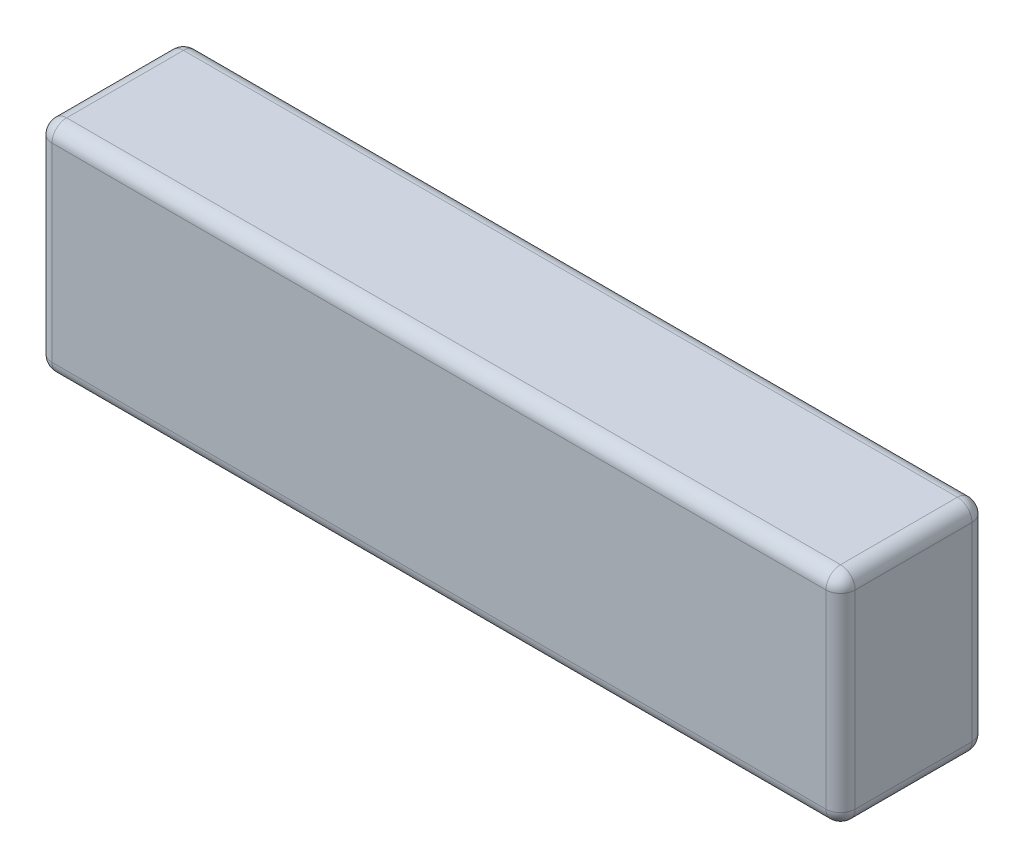
from build123d import *

# Parameters (mm, degrees)
SKETCH1_W           = 165
SKETCH1_H           = 45
BOSS_EXTRUDE1_DEPTH = 30
FILLET1_R           = 3
SKETCH3_W           = 0.673076923
SKETCH3_H           = 3.58974359
CUT_EXTRUDE1_DEPTH  = 1


with BuildPart() as part:
    # Sketch1 → Boss-Extrude1 (new body)
    with BuildSketch(Plane.XY):
        Rectangle(SKETCH1_W, SKETCH1_H)
    extrude(amount=BOSS_EXTRUDE1_DEPTH)

    # Fillet1
    fillet1_edges = [part.edges().sort_by_distance(p)[0] for p in [
        (-82.5, 0, 30),
        (0, -22.5, 30),
        (82.5, 0, 30),
        (0, -22.5, 0),
        (-82.5, 0, 0),
        (0, 22.5, 0),
        (82.5, 0, 0),
        (82.5, -22.5, 15),
        (-82.5, -22.5, 15),
        (-82.5, 22.5, 15),
        (82.5, 22.5, 15),
        (0, 22.5, 30),
    ]]
    fillet(fillet1_edges, radius=FILLET1_R)

    # Sketch3 → Cut-Extrude1 (cut)
    with BuildSketch(Plane(origin=(0, 0, 0), x_dir=(-1, 0, 0), z_dir=(0, 0, -1))):
        with BuildLine():
            Line((-71.893671292, 13.895700482), (-71.280189722, 14.073084296))
            add(Edge.make_bspline(
                [(-71.280189722, 14.073084296), (-71.225871314, 14.026443619), (-71.11859737, 13.934332501), (-70.945097923, 13.816329924), (-70.766422915, 13.715059698), (-70.581148594, 13.63270496), (-70.389377495, 13.5683925), (-70.191163217, 13.52318746), (-69.986740392, 13.49481596), (-69.84835797, 13.491451935), (-69.778386837, 13.489750962)],
                knots=[0, 0, 0, 0, 1.041270537, 2.056415149, 3.04785222, 4.02691907, 5.002476125, 5.986793017, 6.982050086, 8, 8, 8, 8], degree=3))
            add(Edge.make_bspline(
                [(-69.778386837, 13.489750962), (-69.718520811, 13.490595629), (-69.600453579, 13.492261472), (-69.426293871, 13.508397473), (-69.257568488, 13.533099502), (-69.096761926, 13.568729231), (-68.947474644, 13.611362634), (-68.815323909, 13.663057693), (-68.701557084, 13.720805312), (-68.607697907, 13.785963271), (-68.532945551, 13.855419315), (-68.479830433, 13.928754235), (-68.444745019, 14.004465283), (-68.440584367, 14.057084306), (-68.438543087, 14.082900001)],
                knots=[0, 0, 0, 0, 1.365842901, 2.693702937, 3.988022121, 5.254898597, 6.449778871, 7.52732281, 8.488639893, 9.354185358, 10.127518264, 10.803926709, 11.413188221, 12, 12, 12, 12], degree=3))
            add(Edge.make_bspline(
                [(-68.438543087, 14.082900001), (-68.439112411, 14.097481047), (-68.440270162, 14.127132398), (-68.453455005, 14.170899726), (-68.472231153, 14.215136997), (-68.500258895, 14.258225052), (-68.534745365, 14.301733666), (-68.578504597, 14.343168824), (-68.627943234, 14.386701505), (-68.665641594, 14.412809149), (-68.685337959, 14.42644968)],
                knots=[0, 0, 0, 0, 0.793399885, 1.613421822, 2.475989874, 3.41027112, 4.408291548, 5.499676526, 6.693649214, 8, 8, 8, 8], degree=3))
            add(Edge.make_bspline(
                [(-68.685337959, 14.42644968), (-68.716434597, 14.446676446), (-68.783238704, 14.490129086), (-68.895335349, 14.551825517), (-69.024674541, 14.616738622), (-69.171169098, 14.685778315), (-69.336143806, 14.755631459), (-69.517927066, 14.830458881), (-69.717496484, 14.907137439), (-69.856838004, 14.958102229), (-69.929128023, 14.984542629)],
                knots=[0, 0, 0, 0, 0.651554612, 1.399718012, 2.246232405, 3.194032661, 4.244274998, 5.393334075, 6.647668484, 8, 8, 8, 8], degree=3))
            add(Edge.make_bspline(
                [(-69.929128023, 14.984542629), (-69.966034542, 14.998150046), (-70.03818007, 15.024750071), (-70.144166452, 15.06282844), (-70.244296243, 15.100823125), (-70.338777419, 15.137486352), (-70.428376271, 15.171491034), (-70.512104805, 15.205700026), (-70.591423778, 15.236350772), (-70.664276575, 15.268020517), (-70.732699706, 15.296269706), (-70.795118504, 15.324353287), (-70.852469629, 15.350341477), (-70.904262321, 15.37506123), (-70.951325938, 15.397408854), (-70.991932824, 15.420808434), (-71.028407185, 15.440155565), (-71.050067787, 15.454158992), (-71.060037478, 15.460604328)],
                knots=[0, 0, 0, 0, 1.536708746, 3.003985981, 4.399603778, 5.720466992, 6.96332443, 8.143356599, 9.253876673, 10.28491013, 11.246410331, 12.14563761, 12.958693125, 13.706093678, 14.387997087, 14.992804235, 15.536419603, 16, 16, 16, 16], degree=3))
            add(Edge.make_bspline(
                [(-71.060037478, 15.460604328), (-71.090549913, 15.480904245), (-71.148884037, 15.519713928), (-71.227209146, 15.583555978), (-71.294817191, 15.64752261), (-71.348696344, 15.714491245), (-71.392146428, 15.781744391), (-71.422738135, 15.850962612), (-71.440879821, 15.921958303), (-71.443602949, 15.969754729), (-71.444953344, 15.993456892)],
                knots=[0, 0, 0, 0, 1.281965709, 2.450881021, 3.532631345, 4.532915139, 5.45200979, 6.327405019, 7.170563115, 8, 8, 8, 8], degree=3))
            add(Edge.make_bspline(
                [(-71.444953344, 15.993456892), (-71.44427483, 16.012198355), (-71.442923955, 16.049511327), (-71.432090545, 16.105020964), (-71.413434595, 16.158884889), (-71.388985904, 16.212189444), (-71.356168838, 16.263375515), (-71.316691868, 16.313376098), (-71.269851875, 16.361801811), (-71.216786678, 16.409288266), (-71.157132258, 16.454942155), (-71.090905368, 16.497433074), (-71.019236456, 16.538047404), (-70.942290796, 16.576849084), (-70.858868809, 16.611672582), (-70.769925263, 16.644470185), (-70.675290914, 16.675420444), (-70.540404354, 16.712882475), (-70.36324456, 16.751922991), (-70.142524092, 16.786573613), (-69.912416763, 16.805966925), (-69.756219345, 16.808814524), (-69.676724177, 16.810263783)],
                knots=[0, 0, 0, 0, 0.533177814, 1.061520582, 1.602115444, 2.15264519, 2.726586989, 3.328082654, 3.963210978, 4.641558391, 5.353326044, 6.098707271, 6.879203721, 7.697260024, 8.549721912, 9.45048688, 10.39496421, 11.38267535, 13.433851354, 15.554349609, 17.737429174, 20, 20, 20, 20], degree=3))
            add(Edge.make_bspline(
                [(-69.676724177, 16.810263783), (-69.592299393, 16.808876627), (-69.425907832, 16.806142703), (-69.180366201, 16.78165738), (-68.943338436, 16.741786215), (-68.750859531, 16.695742834), (-68.599683291, 16.648660214), (-68.484793001, 16.607660889), (-68.368885975, 16.558591791), (-68.250840835, 16.504003787), (-68.131379942, 16.44236293), (-68.010317125, 16.373947626), (-67.887775806, 16.299115369), (-67.806658115, 16.245196251), (-67.765466164, 16.217815866)],
                knots=[0, 0, 0, 0, 1.493185142, 2.942896577, 4.360030623, 5.74281349, 6.439800385, 7.160372375, 7.899781663, 8.665559224, 9.460651888, 10.277042986, 11.125074197, 12, 12, 12, 12], degree=3))
            Line((-67.765466164, 16.217815866), (-68.354408472, 16.002571475))
            add(Edge.make_bspline(
                [(-68.354408472, 16.002571475), (-68.387938207, 16.024733576), (-68.453069722, 16.067783461), (-68.550217321, 16.127439043), (-68.643106415, 16.181505429), (-68.732488681, 16.229339136), (-68.818004729, 16.271602827), (-68.899934038, 16.307912511), (-68.977780392, 16.339373795), (-69.077640812, 16.371845173), (-69.202630714, 16.404448241), (-69.357346339, 16.431801889), (-69.518391008, 16.447971016), (-69.62807622, 16.450172362), (-69.683735395, 16.451289424)],
                knots=[0, 0, 0, 0, 1.01325678, 1.968251433, 2.873777025, 3.72260486, 4.523687185, 5.27809884, 5.981646049, 6.639388114, 7.924189992, 9.234888461, 10.596858935, 12, 12, 12, 12], degree=3))
            add(Edge.make_bspline(
                [(-69.683735395, 16.451289424), (-69.719497069, 16.450816342), (-69.789428885, 16.449891231), (-69.891957304, 16.444695669), (-69.989456255, 16.433878832), (-70.082073923, 16.41986813), (-70.169894664, 16.403037039), (-70.252250227, 16.379903526), (-70.330068619, 16.354609809), (-70.401882811, 16.324505231), (-70.466746691, 16.291846404), (-70.524003422, 16.257596473), (-70.572917446, 16.221668411), (-70.612033298, 16.18223911), (-70.643503611, 16.141855096), (-70.665640182, 16.098837794), (-70.679876592, 16.054184338), (-70.681382768, 16.023473969), (-70.682132831, 16.008180449)],
                knots=[0, 0, 0, 0, 1.453597553, 2.842504444, 4.170504916, 5.438658546, 6.649524212, 7.801703064, 8.913104635, 9.973318417, 10.963111014, 11.862343011, 12.683042548, 13.421876713, 14.113400648, 14.754904574, 15.379952374, 16, 16, 16, 16], degree=3))
            add(Edge.make_bspline(
                [(-70.682132831, 16.008180449), (-70.680843563, 15.98933836), (-70.678222367, 15.951030707), (-70.658586135, 15.894663115), (-70.627801081, 15.839213074), (-70.583460936, 15.783886791), (-70.522532208, 15.728231378), (-70.442333903, 15.672235217), (-70.342780423, 15.613326149), (-70.268499403, 15.576034468), (-70.22850703, 15.555956892)],
                knots=[0, 0, 0, 0, 0.670740552, 1.363675461, 2.105758115, 2.924217645, 3.879278919, 5.03765473, 6.405094373, 8, 8, 8, 8], degree=3))
            add(Edge.make_bspline(
                [(-70.22850703, 15.555956892), (-70.22172353, 15.552933402), (-70.206531136, 15.546161963), (-70.181617855, 15.534626535), (-70.150893563, 15.523397599), (-70.11623971, 15.507800912), (-70.075319499, 15.493133325), (-70.029833953, 15.475386342), (-69.979462175, 15.455703652), (-69.924071504, 15.434669534), (-69.86361443, 15.41242903), (-69.79839038, 15.387549386), (-69.727735354, 15.361805261), (-69.651872304, 15.334620091), (-69.571418222, 15.304924263), (-69.485694703, 15.274356097), (-69.395238768, 15.241021834), (-69.332963717, 15.218887556), (-69.300922895, 15.20749936)],
                knots=[0, 0, 0, 0, 0.359733916, 0.80566378, 1.32905273, 1.942911142, 2.64507461, 3.433374686, 4.307824936, 5.264358505, 6.303026488, 7.427805646, 8.645357254, 9.945110068, 11.330930719, 12.798956541, 14.353047294, 16, 16, 16, 16], degree=3))
            add(Edge.make_bspline(
                [(-69.300922895, 15.20749936), (-69.226287183, 15.179909903), (-69.082448241, 15.126739132), (-68.876473322, 15.046545776), (-68.688934732, 14.968086865), (-68.519968919, 14.89171346), (-68.368847587, 14.818423919), (-68.23613182, 14.747368183), (-68.121840328, 14.677922983), (-68.024646019, 14.610219674), (-67.942075528, 14.543502494), (-67.871481027, 14.477450971), (-67.811440303, 14.411488738), (-67.76182884, 14.345605846), (-67.723033673, 14.279196691), (-67.696506072, 14.212221478), (-67.679110965, 14.145240161), (-67.676846393, 14.100296115), (-67.675722574, 14.077992148)],
                knots=[0, 0, 0, 0, 1.843695315, 3.55319427, 5.12107753, 6.55338853, 7.849057223, 9.012043014, 10.040127331, 10.946003584, 11.75450491, 12.497696113, 13.183962156, 13.81861519, 14.405647643, 14.959710222, 15.483745, 16, 16, 16, 16], degree=3))
            add(Edge.make_bspline(
                [(-67.675722574, 14.077992148), (-67.677418181, 14.046460434), (-67.680826846, 13.983072486), (-67.710794548, 13.890544671), (-67.75803117, 13.801406147), (-67.824773507, 13.716015167), (-67.909843706, 13.634047468), (-68.01319601, 13.555565332), (-68.134912607, 13.480727834), (-68.272978007, 13.40955985), (-68.424473002, 13.344651568), (-68.585436738, 13.286853748), (-68.754816185, 13.238579869), (-68.932390646, 13.199664089), (-69.117743142, 13.168891518), (-69.310990743, 13.146491267), (-69.512231773, 13.132949074), (-69.649125473, 13.131509308), (-69.718791485, 13.130776603)],
                knots=[0, 0, 0, 0, 0.621934605, 1.250270078, 1.903271797, 2.608273976, 3.382510854, 4.232570092, 5.168347055, 6.203491189, 7.300199682, 8.423868034, 9.581927108, 10.778977832, 12.015378563, 13.29434445, 14.623075938, 16, 16, 16, 16], degree=3))
            add(Edge.make_bspline(
                [(-69.718791485, 13.130776603), (-69.772791358, 13.131278711), (-69.879688768, 13.132272678), (-70.038195598, 13.141303184), (-70.192906161, 13.153799841), (-70.34362058, 13.174163646), (-70.490620672, 13.198168518), (-70.633992009, 13.228493432), (-70.773460445, 13.264109036), (-70.909235277, 13.305521371), (-71.041895881, 13.35322799), (-71.171412192, 13.408817331), (-71.298743478, 13.471085595), (-71.422863866, 13.541750004), (-71.54517312, 13.618609532), (-71.66416896, 13.703824708), (-71.781230791, 13.795667565), (-71.855916686, 13.86211202), (-71.893671292, 13.895700482)],
                knots=[0, 0, 0, 0, 1.096296697, 2.170213931, 3.222763126, 4.246882936, 5.257112168, 6.246395899, 7.221200436, 8.17885356, 9.12750623, 10.082050695, 11.03913936, 12.003808695, 12.980620737, 13.970768988, 14.97419962, 16, 16, 16, 16], degree=3))
        make_face()
        Polygon((-66.284696933, 16.810263783), (-65.61162001, 16.810263783), (-65.61162001, 14.794538623), (-63.253046292, 15.778212501), (-62.156491805, 15.778212501), (-65.061940523, 14.566674039), (-61.977004626, 13.220520193), (-63.044813119, 13.220520193), (-65.61162001, 14.340211699), (-65.61162001, 13.220520193), (-66.284696933, 13.220520193), align=None)
        Polygon((-61.797517446, 15.778212501), (-61.010858792, 15.778212501), (-59.277685715, 13.846621956), (-57.469492607, 15.778212501), (-56.682132831, 15.778212501), (-59.957773857, 12.278212501), (-60.745133632, 12.278212501), (-59.678727382, 13.417535417), align=None)
        with BuildLine():
            Line((-49.009055908, 16.078292629), (-49.578366805, 15.867956091))
            add(Edge.make_bspline(
                [(-49.578366805, 15.867956091), (-49.617864679, 15.89150653), (-49.697862688, 15.939205004), (-49.823610036, 16.003872473), (-49.95497603, 16.065105424), (-50.092251172, 16.121846706), (-50.2355662, 16.173544941), (-50.384310964, 16.221216035), (-50.53887733, 16.26476068), (-50.699128716, 16.303734919), (-50.864162448, 16.338774073), (-51.033448919, 16.368998303), (-51.206776214, 16.393937699), (-51.384172004, 16.415240431), (-51.565884309, 16.43101972), (-51.751477821, 16.443076227), (-51.941089683, 16.450249645), (-52.068745366, 16.450940373), (-52.133254626, 16.451289424)],
                knots=[0, 0, 0, 0, 0.832057853, 1.685229226, 2.557559538, 3.454549684, 4.372387607, 5.314045451, 6.28078757, 7.277890472, 8.298216576, 9.333631855, 10.389364328, 11.466932833, 12.566692778, 13.68982298, 14.832579901, 16, 16, 16, 16], degree=3))
            add(Edge.make_bspline(
                [(-52.133254626, 16.451289424), (-52.203847878, 16.450893759), (-52.343703141, 16.450109891), (-52.551529247, 16.439498875), (-52.755453508, 16.424523693), (-52.955407248, 16.402835796), (-53.151262914, 16.374438272), (-53.343470345, 16.341460745), (-53.531492367, 16.300130164), (-53.714819721, 16.254708133), (-53.89082784, 16.202850139), (-54.057879491, 16.146892826), (-54.214821521, 16.087023152), (-54.361257286, 16.022302205), (-54.49750797, 15.953602216), (-54.624175788, 15.881075811), (-54.739796182, 15.803047084), (-54.845302315, 15.721945663), (-54.939488321, 15.637455938), (-55.021068613, 15.549634789), (-55.090958643, 15.459524484), (-55.146900502, 15.365768585), (-55.192061591, 15.270264056), (-55.222819145, 15.17135352), (-55.242668053, 15.070175279), (-55.245044216, 15.001461193), (-55.246235395, 14.967014584)],
                knots=[0, 0, 0, 0, 1.35894126, 2.692255708, 4.005320711, 5.295216345, 6.563387883, 7.815000734, 9.048758551, 10.268796017, 11.450523255, 12.580260719, 13.659856825, 14.683193395, 15.661129759, 16.596487908, 17.491248672, 18.344429989, 19.156782388, 19.924073768, 20.649414523, 21.347751497, 22.022137988, 22.678142214, 23.337348132, 24, 24, 24, 24], degree=3))
            add(Edge.make_bspline(
                [(-55.246235395, 14.967014584), (-55.245550676, 14.94104042), (-55.24418182, 14.88911419), (-55.233496859, 14.812312636), (-55.215653483, 14.737048029), (-55.191262196, 14.663493953), (-55.159314609, 14.59156771), (-55.120758053, 14.521340724), (-55.074752419, 14.453032604), (-55.021897784, 14.386559141), (-54.962793702, 14.320841467), (-54.896127651, 14.257233235), (-54.822056076, 14.19558827), (-54.741541926, 14.135087795), (-54.653301107, 14.077495143), (-54.559697202, 14.019125238), (-54.45728858, 13.965273715), (-54.311765424, 13.892269538), (-54.116890448, 13.810167087), (-53.870556145, 13.723396061), (-53.609050549, 13.652026022), (-53.3334312, 13.592139849), (-53.043123935, 13.546285458), (-52.737971553, 13.513922557), (-52.418442494, 13.492797743), (-52.200363242, 13.490780368), (-52.089083953, 13.489750962)],
                knots=[0, 0, 0, 0, 0.494370405, 0.98832018, 1.472882881, 1.965327473, 2.461356877, 2.969139921, 3.488658368, 4.027186184, 4.58476761, 5.170079946, 5.779630732, 6.418547357, 7.086146329, 7.785121752, 8.517686603, 9.28773273, 10.884402948, 12.539210585, 14.256613756, 16.041261488, 17.90652187, 19.848797664, 21.881766188, 24, 24, 24, 24], degree=3))
            add(Edge.make_bspline(
                [(-52.089083953, 13.489750962), (-52.027143512, 13.490075081), (-51.904623831, 13.490716197), (-51.722760722, 13.498242142), (-51.544801848, 13.50898552), (-51.370674499, 13.525466965), (-51.200157355, 13.545425822), (-51.033519064, 13.570909117), (-50.870662534, 13.59998272), (-50.712019834, 13.634716309), (-50.556846263, 13.672961415), (-50.405648711, 13.716583289), (-50.25795664, 13.764123824), (-50.114472633, 13.816806733), (-49.974472184, 13.873523086), (-49.838736465, 13.935344314), (-49.70630331, 14.00100215), (-49.620932963, 14.049101618), (-49.578366805, 14.073084296)],
                knots=[0, 0, 0, 0, 1.140222871, 2.255388252, 3.35037711, 4.421964116, 5.47487885, 6.510510447, 7.524904211, 8.519850335, 9.499695433, 10.466551297, 11.41625365, 12.355430759, 13.279827392, 14.196360784, 15.100694874, 16, 16, 16, 16], degree=3))
            Line((-49.578366805, 14.073084296), (-49.009055908, 13.864851123))
            add(Edge.make_bspline(
                [(-49.009055908, 13.864851123), (-49.054825345, 13.836118794), (-49.147820739, 13.77773979), (-49.294350146, 13.697503503), (-49.449091896, 13.622348909), (-49.612306671, 13.55233779), (-49.783598154, 13.486415519), (-49.963424471, 13.426422942), (-50.151154406, 13.370812358), (-50.346919074, 13.320648726), (-50.549853567, 13.275776032), (-50.758995643, 13.237477751), (-50.973860034, 13.204496581), (-51.194547252, 13.177123979), (-51.421120441, 13.156110929), (-51.653541657, 13.141755838), (-51.891753582, 13.132144954), (-52.052616005, 13.131236142), (-52.133955748, 13.130776603)],
                knots=[0, 0, 0, 0, 0.79749538, 1.620369399, 2.464253432, 3.33571117, 4.240903746, 5.172469216, 6.132951178, 7.130228392, 8.154650082, 9.199958019, 10.267878835, 11.362763131, 12.481742405, 13.62581771, 14.799499758, 16, 16, 16, 16], degree=3))
            add(Edge.make_bspline(
                [(-52.133955748, 13.130776603), (-52.211321303, 13.131030375), (-52.363756041, 13.131530387), (-52.589308243, 13.139984802), (-52.80862192, 13.151331554), (-53.021999517, 13.168600812), (-53.229270622, 13.188848134), (-53.430195721, 13.216138509), (-53.624837867, 13.246426889), (-53.813269535, 13.282386366), (-53.995459092, 13.322890018), (-54.171597297, 13.368331438), (-54.341434623, 13.419149408), (-54.505416313, 13.473275791), (-54.662964272, 13.533212267), (-54.81435837, 13.597597766), (-54.959873294, 13.666653323), (-55.052956929, 13.717637244), (-55.098999818, 13.74285593)],
                knots=[0, 0, 0, 0, 1.213580145, 2.39113869, 3.54036773, 4.658377055, 5.749147901, 6.806911622, 7.838817416, 8.839006368, 9.815662487, 10.766248167, 11.69191758, 12.596227374, 13.474607217, 14.335357622, 15.176601312, 16, 16, 16, 16], degree=3))
            add(Edge.make_bspline(
                [(-55.098999818, 13.74285593), (-55.135904772, 13.76424242), (-55.208317803, 13.806205907), (-55.311181304, 13.873826241), (-55.407649165, 13.94238911), (-55.496644604, 14.013009315), (-55.578219125, 14.085693657), (-55.653362399, 14.158922422), (-55.721467067, 14.234271301), (-55.781046495, 14.312355833), (-55.836147241, 14.390428855), (-55.881237682, 14.471857774), (-55.921051814, 14.55398038), (-55.953478373, 14.638104202), (-55.977687453, 14.72415437), (-55.996466546, 14.811392432), (-56.006987837, 14.900615039), (-56.008364383, 14.960678906), (-56.009055908, 14.990852725)],
                knots=[0, 0, 0, 0, 1.261288684, 2.474836709, 3.639118363, 4.760699908, 5.832955594, 6.869160426, 7.862786844, 8.833354565, 9.77280558, 10.685873618, 11.582441056, 12.470737374, 13.348020378, 14.22374992, 15.107679, 16, 16, 16, 16], degree=3))
            add(Edge.make_bspline(
                [(-56.009055908, 14.990852725), (-56.008341541, 15.022690535), (-56.00692216, 15.085949393), (-55.992637379, 15.179462616), (-55.971959126, 15.271380315), (-55.941683266, 15.361377497), (-55.901884165, 15.448958754), (-55.85500428, 15.535217122), (-55.798202066, 15.618681481), (-55.733689598, 15.700800395), (-55.660459145, 15.781071578), (-55.577910473, 15.858680895), (-55.487484565, 15.935173729), (-55.388255468, 16.009647702), (-55.280170101, 16.081657259), (-55.163416722, 16.151627272), (-55.038663902, 16.22041239), (-54.905735365, 16.286666928), (-54.766368767, 16.350066636), (-54.621830412, 16.409658591), (-54.473088004, 16.465028133), (-54.319950232, 16.516318704), (-54.162306887, 16.563193903), (-54.000157968, 16.605734906), (-53.834028986, 16.645198182), (-53.663558956, 16.680145971), (-53.488688382, 16.711060783), (-53.309349188, 16.737559576), (-53.125599512, 16.760057475), (-52.937596723, 16.777909729), (-52.745508865, 16.793178613), (-52.548852219, 16.802331106), (-52.347845741, 16.809152799), (-52.212253853, 16.809890964), (-52.143771453, 16.810263783)],
                knots=[0, 0, 0, 0, 0.659329485, 1.310028209, 1.956204997, 2.610193958, 3.273584605, 3.947708608, 4.642194565, 5.363065683, 6.110441927, 6.891550722, 7.709509354, 8.563867986, 9.461186493, 10.399787503, 11.383919325, 12.412764344, 13.4769796, 14.556296761, 15.652049855, 16.765513838, 17.902544871, 19.059698289, 20.239168583, 21.440746263, 22.665411752, 23.918881692, 25.19725597, 26.501354349, 27.832310404, 29.190128443, 30.580838778, 32, 32, 32, 32], degree=3))
            add(Edge.make_bspline(
                [(-52.143771453, 16.810263783), (-52.061264669, 16.809781265), (-51.898068898, 16.808826861), (-51.656550972, 16.799552339), (-51.420915271, 16.784012446), (-51.191565073, 16.763073067), (-50.967914733, 16.736872563), (-50.75080296, 16.702876611), (-50.539636096, 16.663780843), (-50.334998796, 16.619019574), (-50.138061669, 16.568876983), (-49.949560541, 16.513433003), (-49.77029587, 16.453036758), (-49.599497416, 16.389267851), (-49.438811915, 16.318374441), (-49.286304363, 16.244844393), (-49.143599527, 16.164634131), (-49.053428291, 16.10676799), (-49.009055908, 16.078292629)],
                knots=[0, 0, 0, 0, 1.214042116, 2.401336365, 3.555880304, 4.688577987, 5.789957796, 6.868749364, 7.921648314, 8.949671115, 9.950577319, 10.911435626, 11.840167239, 12.733729607, 13.593071714, 14.423607865, 15.22427286, 16, 16, 16, 16], degree=3))
        make_face()
        with BuildLine():
            Line((-43.126644049, 14.028212501), (-42.547517446, 13.881678046))
            add(Edge.make_bspline(
                [(-42.547517446, 13.881678046), (-42.596608157, 13.841718406), (-42.695350272, 13.761342725), (-42.857391916, 13.656826843), (-43.029200444, 13.562159093), (-43.213373935, 13.481267456), (-43.40840922, 13.410446066), (-43.614841896, 13.349191168), (-43.832828816, 13.295678043), (-44.063306504, 13.251582645), (-44.307597206, 13.217323193), (-44.566584673, 13.193212467), (-44.840943623, 13.178270807), (-45.029001388, 13.176537966), (-45.125542286, 13.175648398)],
                knots=[0, 0, 0, 0, 0.834967428, 1.679471499, 2.540934055, 3.422035412, 4.331585971, 5.278305527, 6.262946599, 7.293291515, 8.374374099, 9.517813741, 10.725750627, 12, 12, 12, 12], degree=3))
            add(Edge.make_bspline(
                [(-45.125542286, 13.175648398), (-45.17976731, 13.17583637), (-45.286604746, 13.176206723), (-45.444839565, 13.181578062), (-45.5984614, 13.188773955), (-45.747789701, 13.200430333), (-45.892345261, 13.213890082), (-46.03252684, 13.231910073), (-46.168247396, 13.251698827), (-46.299534003, 13.275934993), (-46.426422467, 13.302086547), (-46.548562769, 13.332642724), (-46.666399429, 13.36510674), (-46.77939971, 13.401957541), (-46.888347701, 13.44093307), (-46.992573692, 13.483752579), (-47.092580069, 13.529322533), (-47.187522763, 13.57809466), (-47.276848982, 13.629820981), (-47.362027629, 13.680254253), (-47.440421332, 13.733005021), (-47.513212631, 13.786537391), (-47.5800118, 13.840942659), (-47.641745786, 13.895503234), (-47.69632361, 13.952134416), (-47.746119621, 14.008420387), (-47.790337085, 14.065781039), (-47.827947627, 14.124275132), (-47.859581618, 14.183807917), (-47.886802404, 14.243418249), (-47.907200547, 14.304542927), (-47.920789682, 14.366657682), (-47.930764428, 14.429169505), (-47.931676453, 14.471281994), (-47.932132831, 14.492355129)],
                knots=[0, 0, 0, 0, 1.549565074, 3.053047274, 4.524243387, 5.944199477, 7.33317225, 8.672722846, 9.982828433, 11.252260969, 12.487498546, 13.684589821, 14.849729736, 15.979729739, 17.080454092, 18.155779607, 19.198823763, 20.220413458, 21.20457324, 22.14840531, 23.048672058, 23.903598836, 24.72973458, 25.510139039, 26.256386003, 26.97578881, 27.657070535, 28.324025995, 28.960488077, 29.582344607, 30.194841225, 30.797573684, 31.398304565, 32, 32, 32, 32], degree=3))
            add(Edge.make_bspline(
                [(-47.932132831, 14.492355129), (-47.930249289, 14.531802996), (-47.926474269, 14.610864945), (-47.895425189, 14.727202052), (-47.845633437, 14.840302544), (-47.774928371, 14.949214564), (-47.685597532, 15.055086723), (-47.576147689, 15.156909669), (-47.44763209, 15.255818149), (-47.352162241, 15.315362905), (-47.302525459, 15.346321475)],
                knots=[0, 0, 0, 0, 0.851345125, 1.706277394, 2.583602241, 3.512395252, 4.501684911, 5.569869874, 6.73652426, 8, 8, 8, 8], degree=3))
            add(Edge.make_bspline(
                [(-47.302525459, 15.346321475), (-47.26882444, 15.365828047), (-47.200651512, 15.40528739), (-47.094071322, 15.458611436), (-46.983640108, 15.509551799), (-46.868969092, 15.556203424), (-46.750040095, 15.599414654), (-46.626632066, 15.637184858), (-46.49953291, 15.673725461), (-46.367875217, 15.704583719), (-46.23218221, 15.733208473), (-46.091920958, 15.756340995), (-45.947805384, 15.777795984), (-45.799312245, 15.794576281), (-45.646604399, 15.806947066), (-45.489743551, 15.816002764), (-45.328676616, 15.821771469), (-45.219964867, 15.822642393), (-45.164805107, 15.823084296)],
                knots=[0, 0, 0, 0, 0.843162448, 1.705611689, 2.579862515, 3.476565579, 4.385992496, 5.319318643, 6.271141209, 7.249601771, 8.247250169, 9.274093453, 10.327781367, 11.402664909, 12.509848096, 13.645553677, 14.805366534, 16, 16, 16, 16], degree=3))
            add(Edge.make_bspline(
                [(-45.164805107, 15.823084296), (-45.108010085, 15.822628587), (-44.996028637, 15.821730077), (-44.830266966, 15.816160927), (-44.668708069, 15.806414637), (-44.511630313, 15.792310252), (-44.35867139, 15.774984443), (-44.210267203, 15.753043766), (-44.065896407, 15.728164842), (-43.926049556, 15.698668716), (-43.790753354, 15.66484889), (-43.659425744, 15.627917314), (-43.532403185, 15.586552193), (-43.40993197, 15.540958418), (-43.291643713, 15.491977899), (-43.178194685, 15.438406546), (-43.068320405, 15.382046907), (-42.998136376, 15.340373866), (-42.963282671, 15.319678847)],
                knots=[0, 0, 0, 0, 1.192332677, 2.350895161, 3.481443095, 4.589723323, 5.661442475, 6.712649064, 7.738673605, 8.736545045, 9.71231579, 10.66594064, 11.599977805, 12.51590187, 13.40885665, 14.286804546, 15.149219414, 16, 16, 16, 16], degree=3))
            add(Edge.make_bspline(
                [(-42.963282671, 15.319678847), (-42.916869459, 15.289931875), (-42.827347918, 15.232556082), (-42.707019454, 15.135028771), (-42.604762379, 15.03195443), (-42.519993885, 14.92332679), (-42.454003021, 14.808550126), (-42.405798618, 14.688307011), (-42.375190471, 14.5620853), (-42.370433302, 14.475696873), (-42.368030267, 14.432058655)],
                knots=[0, 0, 0, 0, 1.182229095, 2.280276844, 3.315733999, 4.291716162, 5.228465184, 6.146654023, 7.063801489, 8, 8, 8, 8], degree=3))
            Line((-42.368030267, 14.432058655), (-47.259055908, 14.432058655))
            add(Edge.make_bspline(
                [(-47.259055908, 14.432058655), (-47.255637474, 14.398163137), (-47.24880603, 14.330425868), (-47.215746234, 14.232435021), (-47.166016157, 14.139134778), (-47.097268365, 14.051947008), (-47.011804817, 13.969196506), (-46.908540373, 13.891337645), (-46.787128506, 13.819185076), (-46.650642004, 13.750891078), (-46.500569689, 13.690180619), (-46.340724343, 13.636133659), (-46.171878223, 13.590590374), (-45.994619936, 13.553758921), (-45.808816993, 13.52490108), (-45.614559901, 13.505158233), (-45.411547922, 13.491973216), (-45.273266951, 13.490502074), (-45.202665683, 13.489750962)],
                knots=[0, 0, 0, 0, 0.667577138, 1.334095343, 2.016124046, 2.736214378, 3.505802213, 4.347970111, 5.270925558, 6.277164528, 7.343913518, 8.448953741, 9.590706626, 10.777668559, 12.004455658, 13.283356727, 14.612980096, 16, 16, 16, 16], degree=3))
            add(Edge.make_bspline(
                [(-45.202665683, 13.489750962), (-45.133706772, 13.490363866), (-44.996864396, 13.491580115), (-44.79291581, 13.503191049), (-44.592045597, 13.522089563), (-44.39583187, 13.547807397), (-44.208157011, 13.579387684), (-44.033264643, 13.617225406), (-43.872805122, 13.65890869), (-43.723604628, 13.706754746), (-43.578521807, 13.764753518), (-43.432552418, 13.838932006), (-43.279401536, 13.92545156), (-43.178781059, 13.9931396), (-43.126644049, 14.028212501)],
                knots=[0, 0, 0, 0, 1.138424917, 2.259095557, 3.371378534, 4.468805117, 5.52561522, 6.512489879, 7.422182984, 8.261691214, 9.09785874, 9.998612954, 10.962971153, 12, 12, 12, 12], degree=3))
        make_face()
        with BuildLine():
            add(Edge.make_bspline(
                [(-43.13085078, 14.746161219), (-43.142968401, 14.767587509), (-43.167021993, 14.810118897), (-43.207783142, 14.870968826), (-43.253844041, 14.927459655), (-43.302445747, 14.981639469), (-43.356021122, 15.031841442), (-43.412838447, 15.079342039), (-43.474550356, 15.122913579), (-43.539826319, 15.163724627), (-43.610075016, 15.201587952), (-43.684816585, 15.238438229), (-43.766133122, 15.271381835), (-43.851739447, 15.304851821), (-43.943520243, 15.334525373), (-44.04017471, 15.36352154), (-44.142430374, 15.389937686), (-44.286328948, 15.422658317), (-44.472410545, 15.458435492), (-44.701730021, 15.486841927), (-44.936604522, 15.506284627), (-45.095119642, 15.508075581), (-45.175321933, 15.508981732)],
                knots=[0, 0, 0, 0, 0.647791161, 1.285871526, 1.924722341, 2.564845326, 3.200132423, 3.855415433, 4.512572456, 5.186782136, 5.880465981, 6.612267823, 7.378818709, 8.188788356, 9.031071868, 9.916628856, 10.844644664, 11.810110062, 13.800748363, 15.828758086, 17.88951894, 20, 20, 20, 20], degree=3))
            add(Edge.make_bspline(
                [(-45.175321933, 15.508981732), (-45.241009129, 15.508377314), (-45.370146169, 15.507189067), (-45.560346764, 15.495789425), (-45.743226783, 15.476784462), (-45.91936568, 15.451433231), (-46.088038518, 15.416415516), (-46.250390065, 15.37662643), (-46.405240986, 15.327317615), (-46.504610007, 15.288423267), (-46.553727382, 15.269198078)],
                knots=[0, 0, 0, 0, 1.119555202, 2.20097759, 3.246233, 4.252968794, 5.232647173, 6.181410095, 7.101084408, 8, 8, 8, 8], degree=3))
            add(Edge.make_bspline(
                [(-46.553727382, 15.269198078), (-46.588110697, 15.254318724), (-46.655719398, 15.225061109), (-46.751159906, 15.17246534), (-46.840725462, 15.115784207), (-46.923985311, 15.053228518), (-47.000296845, 14.984322136), (-47.070500466, 14.910436295), (-47.135408644, 14.831947822), (-47.171978853, 14.774842132), (-47.190345972, 14.746161219)],
                knots=[0, 0, 0, 0, 1.072651343, 2.109178925, 3.117609435, 4.10708427, 5.088372089, 6.059098243, 7.025196356, 8, 8, 8, 8], degree=3))
            Line((-47.190345972, 14.746161219), (-43.13085078, 14.746161219))
        make_face(mode=Mode.SUBTRACT)
        with Locations((-40.864825139, 15.015391988)):
            Rectangle(SKETCH3_W, SKETCH3_H)
        with Locations((-38.84559437, 15.015391988)):
            Rectangle(SKETCH3_W, SKETCH3_H)
        Polygon((-33.190345972, 16.720520193), (-31.778286677, 16.720520193), (-31.778286677, 13.220520193), (-32.496235395, 13.220520193), (-32.496235395, 16.361545834), (-33.618030267, 16.361545834), align=None)
        Polygon((-27.626243408, 16.720520193), (-26.214184113, 16.720520193), (-26.214184113, 13.220520193), (-26.932132831, 13.220520193), (-26.932132831, 16.361545834), (-28.053927703, 16.361545834), align=None)
        with BuildLine():
            add(Edge.make_bspline(
                [(-22.422517446, 13.758981732), (-22.382276313, 13.757831656), (-22.304290166, 13.755602842), (-22.191757381, 13.740593159), (-22.088466637, 13.71385064), (-22.009754402, 13.682921359), (-21.953517914, 13.653498608), (-21.917155885, 13.630807113), (-21.886468345, 13.606503953), (-21.860710329, 13.581692658), (-21.841782988, 13.554430467), (-21.827159898, 13.526863297), (-21.818338107, 13.497525597), (-21.817280091, 13.477421565), (-21.816748215, 13.467315065)],
                knots=[0, 0, 0, 0, 1.990507798, 3.857546318, 5.601569732, 7.256660921, 8.027130436, 8.73909373, 9.372800607, 9.961351037, 10.500235976, 11.006911429, 11.500764338, 12, 12, 12, 12], degree=3))
            add(Edge.make_bspline(
                [(-21.816748215, 13.467315065), (-21.817272901, 13.45743739), (-21.818316939, 13.437782437), (-21.827321353, 13.40898644), (-21.841766845, 13.38159775), (-21.860714165, 13.354339023), (-21.886471636, 13.329536912), (-21.917136021, 13.305187491), (-21.953700765, 13.282642075), (-22.009411638, 13.252005732), (-22.08854637, 13.221587455), (-22.191795426, 13.19491085), (-22.304229218, 13.178789185), (-22.382266648, 13.176717137), (-22.422517446, 13.175648398)],
                knots=[0, 0, 0, 0, 0.48835869, 0.971753697, 1.4790861, 2.018669752, 2.607983289, 3.242511825, 3.955398243, 4.732318271, 6.389555434, 8.135840131, 10.00691133, 12, 12, 12, 12], degree=3))
            add(Edge.make_bspline(
                [(-22.422517446, 13.175648398), (-22.462768244, 13.176717137), (-22.540805675, 13.178789185), (-22.653239466, 13.19491085), (-22.756488523, 13.221587455), (-22.835623255, 13.252005732), (-22.891334127, 13.282642075), (-22.927898872, 13.305187491), (-22.958563256, 13.329536912), (-22.984320728, 13.354339023), (-23.003268048, 13.38159775), (-23.017713539, 13.40898644), (-23.026717954, 13.437782437), (-23.027761992, 13.45743739), (-23.028286677, 13.467315065)],
                knots=[0, 0, 0, 0, 1.99308867, 3.864159869, 5.610444566, 7.267681729, 8.044601757, 8.757488175, 9.392016711, 9.981330248, 10.5209139, 11.028246303, 11.51164131, 12, 12, 12, 12], degree=3))
            add(Edge.make_bspline(
                [(-23.028286677, 13.467315065), (-23.027754802, 13.477421565), (-23.026696786, 13.497525597), (-23.017874994, 13.526863297), (-23.003251905, 13.554430467), (-22.984324564, 13.581692658), (-22.958566547, 13.606503953), (-22.927879007, 13.630807113), (-22.891516979, 13.653498608), (-22.835280491, 13.682921359), (-22.756568255, 13.71385064), (-22.653277511, 13.740593159), (-22.540744727, 13.755602842), (-22.462758579, 13.757831656), (-22.422517446, 13.758981732)],
                knots=[0, 0, 0, 0, 0.499235662, 0.993088571, 1.499764024, 2.038648963, 2.627199393, 3.26090627, 3.972869564, 4.743339079, 6.398430268, 8.142453682, 10.009492202, 12, 12, 12, 12], degree=3))
        make_face()
        Polygon((-19.280089562, 16.720520193), (-17.868030267, 16.720520193), (-17.868030267, 13.220520193), (-18.585978985, 13.220520193), (-18.585978985, 16.361545834), (-19.707773857, 16.361545834), align=None)
        Polygon((-15.265466164, 16.720520193), (-14.485117607, 16.720520193), (-12.102004626, 14.026810257), (-9.718891645, 16.720520193), (-8.938543087, 16.720520193), (-12.034696933, 13.220520193), (-12.169312318, 13.220520193), align=None)
    extrude(amount=-CUT_EXTRUDE1_DEPTH, mode=Mode.SUBTRACT)


solid = part.part
